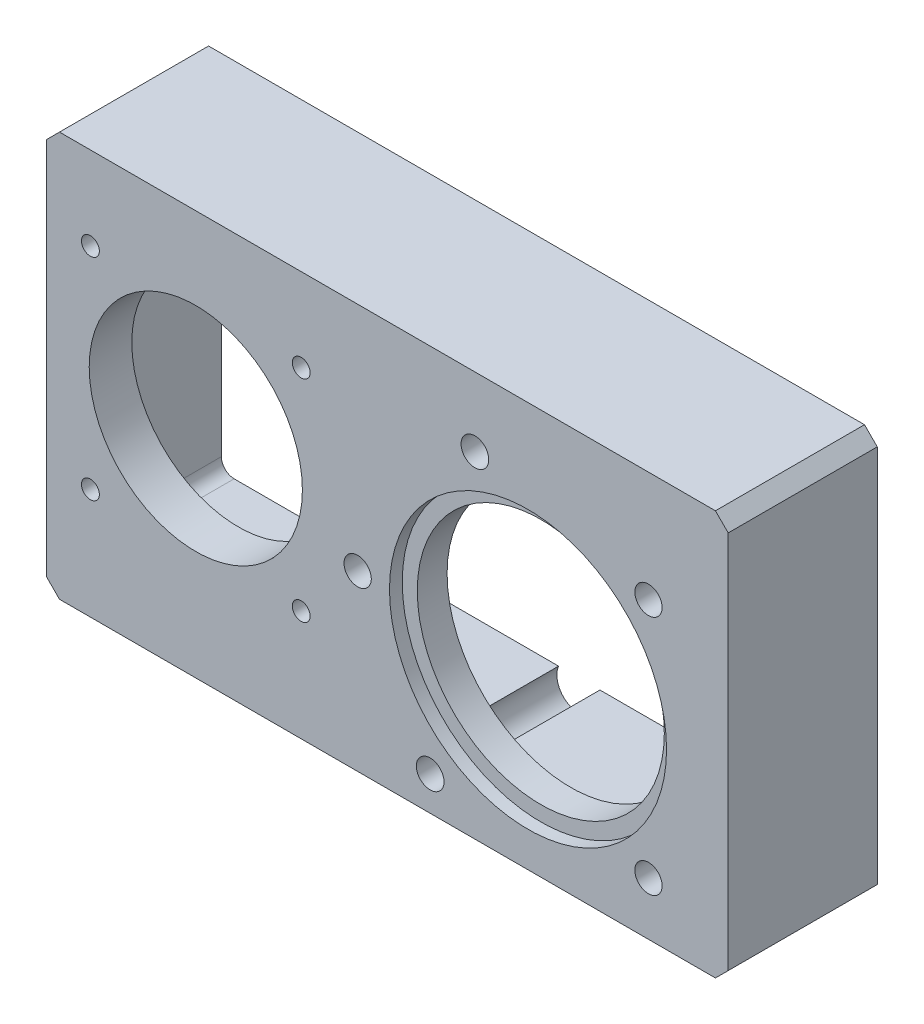
from build123d import *

# Parameters (mm, degrees)
EXTRUDE_1_DEPTH        = 35
SKETCH_4_W             = 142
SKETCH_4_H             = 75
CUT_EXTRUDE_2_DEPTH    = 25
SKETCH_5_R             = 29
CUT_EXTRUDE_3_DEPTH    = 11
CHAMFER_3_SIZE         = 3
FILLET_2_R             = 3
SKETCH_7_R             = 3.2
SKETCH_7_R_2           = 3.25
CUT_EXTRUDE_4_DEPTH    = 11
SKETCH_8_R             = 25.025
CUT_EXTRUDE_5_DEPTH    = 11
SKETCH_9_R             = 5.25
CUT_EXTRUDE_6_DEPTH    = 25
HOLE_WIZARD_M6_1_D     = 5
HOLE_WIZARD_M6_1_DEPTH = 15
HOLE_WIZARD_M6_1_TIP   = 1.502151548
HOLE_WIZARD_M5_1_D     = 4.2
SKETCH_17_R            = 32.525
CUT_EXTRUDE_7_DEPTH    = 3


with BuildPart() as part:
    # 草图1 → 凸台-拉伸1 (new body)
    with BuildSketch(Plane.XY):
        Polygon((0, 0), (0, -60), (160, -60), (160, 35), (68, 35), (0, 35), align=None)
    extrude(amount=EXTRUDE_1_DEPTH)

    # 草图4 → 切除-拉伸2 (cut)
    with BuildSketch(Plane(origin=(0, 0, 0), x_dir=(-1, 0, 0), z_dir=(0, 0, -1))):
        with Locations((-77, -12.5)):
            Rectangle(SKETCH_4_W, SKETCH_4_H)
    extrude(amount=-CUT_EXTRUDE_2_DEPTH, mode=Mode.SUBTRACT)

    # 草图5 → 切除-拉伸3 (cut, through all)
    with BuildSketch(Plane(origin=(0, 0, 25), x_dir=(-1, 0, 0), z_dir=(0, 0, -1))):
        with Locations((-113, -19.25)):
            Circle(SKETCH_5_R)
    extrude(amount=-CUT_EXTRUDE_3_DEPTH, mode=Mode.SUBTRACT)

    # 倒角3
    chamfer_3_edges = [part.edges().sort_by_distance(p)[0] for p in [
        (0, 35, 17.5),
        (160, 35, 17.5),
        (160, -60, 17.5),
        (0, -60, 17.5),
    ]]
    chamfer(chamfer_3_edges, length=CHAMFER_3_SIZE)

    # 圆角2
    fillet_2_edges = [part.edges().sort_by_distance(p)[0] for p in [
        (6, 25, 12.5),
        (6, -50, 12.5),
        (148, -50, 12.5),
        (148, 25, 12.5),
    ]]
    fillet(fillet_2_edges, radius=FILLET_2_R)

    # 草图7 → 切除-拉伸4 (cut, through all)
    with BuildSketch(Plane(origin=(0, 0, 25), x_dir=(-1, 0, 0), z_dir=(0, 0, -1))):
        with Locations((-73, -19.25)):
            Circle(SKETCH_7_R)
        with Locations((-141.284271247, -47.534271247)):
            Circle(SKETCH_7_R)
        with Locations((-141.284271247, 9.034271247)):
            Circle(SKETCH_7_R)
        with Locations((-100.534490363, 18.758039538)):
            Circle(SKETCH_7_R_2)
        with Locations((-90.025808003, -51.994259071)):
            Circle(SKETCH_7_R_2)
    extrude(amount=-CUT_EXTRUDE_4_DEPTH, mode=Mode.SUBTRACT)

    # 草图8 → 切除-拉伸5 (cut, through all)
    with BuildSketch(Plane(origin=(0, 0, 25), x_dir=(-1, 0, 0), z_dir=(0, 0, -1))):
        with Locations((-35, -9.275)):
            Circle(SKETCH_8_R)
    extrude(amount=-CUT_EXTRUDE_5_DEPTH, mode=Mode.SUBTRACT)

    # 草图9 → 切除-拉伸6 (cut)
    with BuildSketch(Plane(origin=(0, 0, 0), x_dir=(-1, 0, 0), z_dir=(0, 0, -1))):
        with Locations((-141.284271247, -47.534271247)):
            Circle(SKETCH_9_R)
        with Locations((-90.025808003, -51.994259071)):
            Circle(SKETCH_9_R)
    extrude(amount=-CUT_EXTRUDE_6_DEPTH, mode=Mode.SUBTRACT)

    # M6 螺纹孔1
    with Locations(Plane(origin=(0, 0, 0), x_dir=(-1, 0, 0), z_dir=(0, 0, -1))):
        with Locations((-154, 29), (-80, 29), (-6, 29), (-154, -54), (-6, -54), (-65, -54)):
            Hole(HOLE_WIZARD_M6_1_D / 2, depth=HOLE_WIZARD_M6_1_DEPTH)
            with Locations((0, 0, -(HOLE_WIZARD_M6_1_DEPTH + HOLE_WIZARD_M6_1_TIP / 2))):  # 118° drill point
                Cone(0, HOLE_WIZARD_M6_1_D / 2, HOLE_WIZARD_M6_1_TIP, mode=Mode.SUBTRACT)

    # M5 螺纹孔1 (through all)
    with Locations(Plane.XY.offset(35)):
        with Locations((10.251262658, 15.473737342), (59.748737342, 15.473737342), (59.748737342, -34.023737342), (10.251262658, -34.023737342)):
            Hole(HOLE_WIZARD_M5_1_D / 2)

    # 草图17 → 切除-拉伸7 (cut)
    with BuildSketch(Plane.XY.offset(35)):
        with Locations((113, -19.25)):
            Circle(SKETCH_17_R)
    extrude(amount=-CUT_EXTRUDE_7_DEPTH, mode=Mode.SUBTRACT)


solid = part.part
